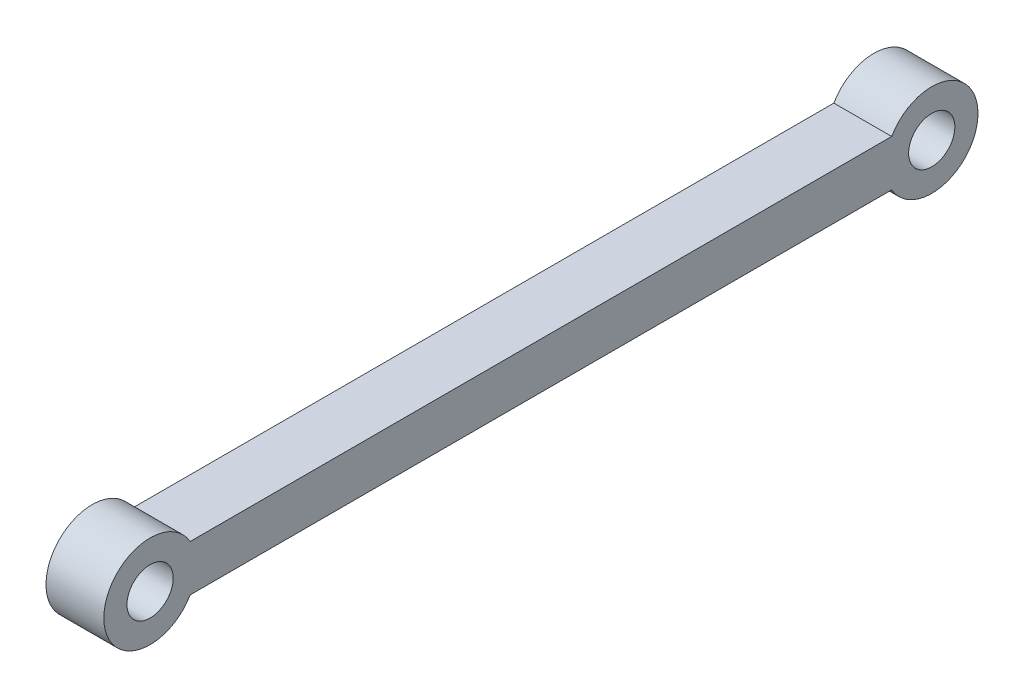
from build123d import *

# Parameters (mm, degrees)
SKETCH1_R           = 1
BOSS_EXTRUDE1_DEPTH = 1.25


with BuildPart() as part:
    # Sketch1 → Boss-Extrude1 (new body, symmetric)
    with BuildSketch(Plane(origin=(0, 0, 0), x_dir=(0, 0, -1), z_dir=(1, 0, 0))):
        with BuildLine():
            Line((-15.162949192, -2), (15.162949192, -2))
            ThreePointArc((15.162949192, -2), (18.895, -1), (15.162949192, 0))
            Line((15.162949192, 0), (-15.162949192, 0))
            ThreePointArc((-15.162949192, 0), (-18.895, -1), (-15.162949192, -2))
        make_face()
        with Locations((-16.895, -1)):
            Circle(SKETCH1_R, mode=Mode.SUBTRACT)
        with Locations((16.895, -1)):
            Circle(SKETCH1_R, mode=Mode.SUBTRACT)
    extrude(amount=BOSS_EXTRUDE1_DEPTH, both=True)


solid = part.part
